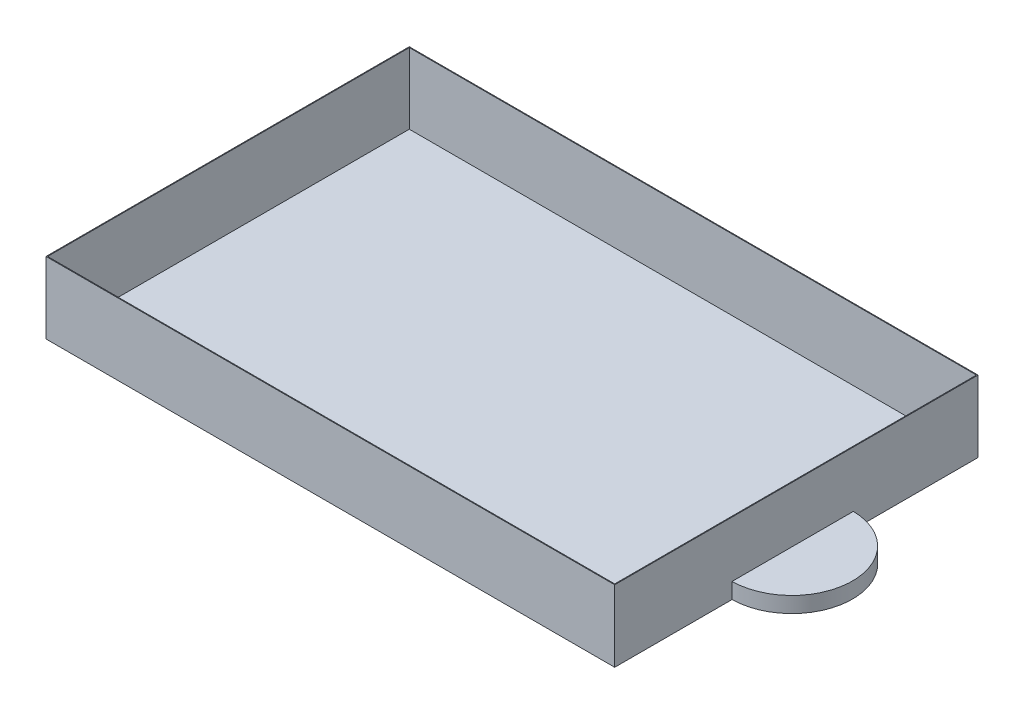
from build123d import *

# Parameters (mm, degrees)
CROQUIS1_W              = 72.404273835
CROQUIS1_H              = 46.251918891
SALIENTE_EXTRUIR1_DEPTH = 9.1
VACIADO2_T              = -0.1
SALIENTE_EXTRUIR2_DEPTH = 2


with BuildPart() as part:
    # Croquis1 → Saliente-Extruir1 (new body)
    with BuildSketch(Plane(origin=(0, 0, 0), x_dir=(1, 0, 0), z_dir=(0, 1, 0))):
        with Locations((36.202136917, 23.125959446)):
            Rectangle(CROQUIS1_W, CROQUIS1_H)
    extrude(amount=SALIENTE_EXTRUIR1_DEPTH)

    # Vaciado2
    vaciado2_openings = [part.faces().sort_by_distance(p)[0] for p in [
        (36.202136917, 9.1, -23.125959446),
    ]]
    offset(amount=VACIADO2_T, openings=vaciado2_openings, kind=Kind.INTERSECTION)

    # Croquis2 → Saliente-Extruir2 (add)
    with BuildSketch(Plane(origin=(0, 0, 0), x_dir=(1, 0, 0), z_dir=(0, 1, 0))):
        with BuildLine():
            Line((72.304273835, 14.936525207), (72.304273835, 30.379638096))
            ThreePointArc((72.304273835, 30.379638096), (80.025830279, 22.658081652), (72.304273835, 14.936525207))
        make_face()
    extrude(amount=SALIENTE_EXTRUIR2_DEPTH)


solid = part.part
